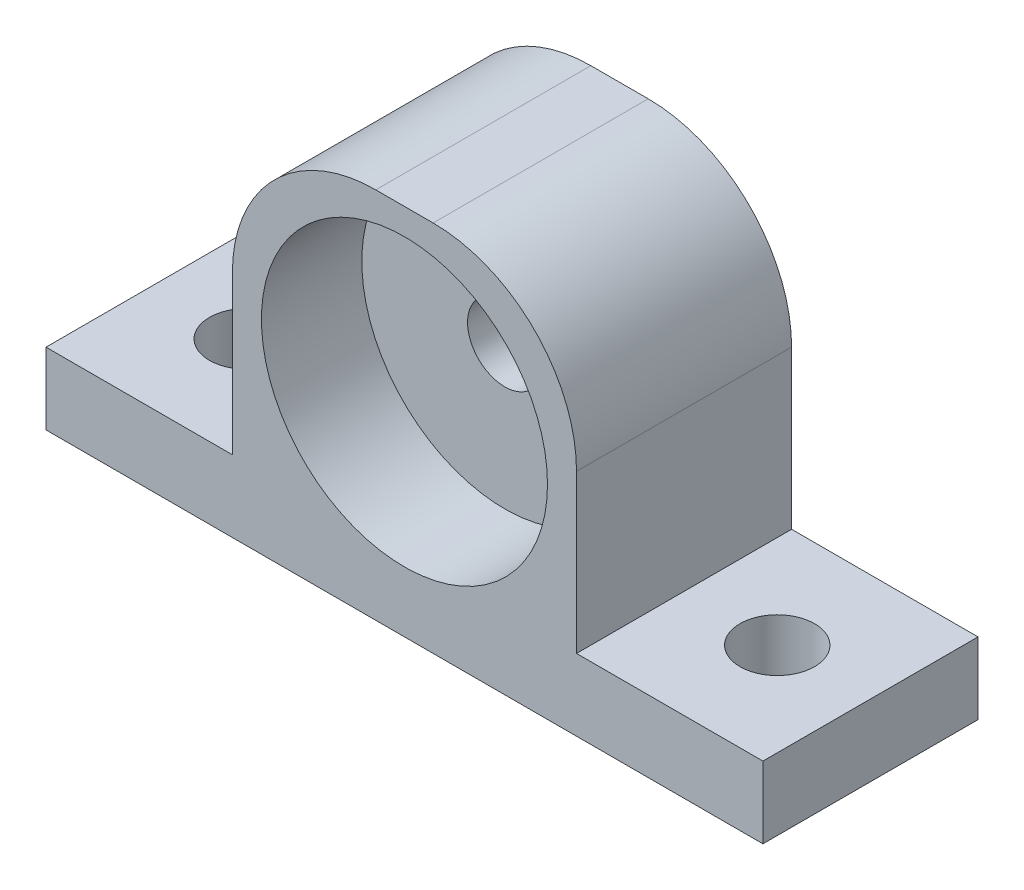
from build123d import *

# Parameters (mm, degrees)
SKETCH1_W           = 63.5
SKETCH1_H           = 19.05
BOSS_EXTRUDE1_DEPTH = 6.35
SKETCH2_W           = 30.48
SKETCH2_H           = 19.05
BOSS_EXTRUDE2_DEPTH = 26.67
CUT_EXTRUDE1_REACH  = 8.35
SKETCH3_R           = 3.302
SKETCH4_R           = 12.669104941
CUT_EXTRUDE2_DEPTH  = 8.89
SKETCH5_R           = 3.302
CUT_EXTRUDE3_DEPTH  = 20.05
FILLET1_R           = 12.7


with BuildPart() as part:
    # Sketch1 → Boss-Extrude1 (new body)
    with BuildSketch(Plane(origin=(0, 0, 0), x_dir=(1, 0, 0), z_dir=(0, 1, 0))):
        with Locations((-30.537406907, 4.286893637)):
            Rectangle(SKETCH1_W, SKETCH1_H)
    extrude(amount=BOSS_EXTRUDE1_DEPTH)

    # Sketch2 → Boss-Extrude2 (add)
    with BuildSketch(Plane(origin=(0, 6.35, 0), x_dir=(1, 0, 0), z_dir=(0, 1, 0))):
        with Locations((-30.537406907, 4.286893637)):
            Rectangle(SKETCH2_W, SKETCH2_H)
    extrude(amount=BOSS_EXTRUDE2_DEPTH)

    # Sketch3 → Cut-Extrude1 (cut, up to next)
    with BuildSketch(Plane(origin=(0, 6.35, 0), x_dir=(1, 0, 0), z_dir=(0, 1, 0)), mode=Mode.PRIVATE) as cut_extrude1_sk1:
        with Locations((-54.032406907, 4.286893637)):
            Circle(SKETCH3_R)
    cut_extrude1_tool1 = extrude(cut_extrude1_sk1.sketch, amount=-CUT_EXTRUDE1_REACH, mode=Mode.PRIVATE) & part.part
    add(cut_extrude1_tool1.solids().sort_by_distance((-54.032407, 6.35, -4.286894))[0], mode=Mode.SUBTRACT)
    # Sketch3 → Cut-Extrude1 (cut, up to next)
    with BuildSketch(Plane(origin=(0, 6.35, 0), x_dir=(1, 0, 0), z_dir=(0, 1, 0)), mode=Mode.PRIVATE) as cut_extrude1_sk2:
        with Locations((-7.042406907, 4.286893637)):
            Circle(SKETCH3_R)
    cut_extrude1_tool2 = extrude(cut_extrude1_sk2.sketch, amount=-CUT_EXTRUDE1_REACH, mode=Mode.PRIVATE) & part.part
    add(cut_extrude1_tool2.solids().sort_by_distance((-7.042407, 6.35, -4.286894))[0], mode=Mode.SUBTRACT)

    # Sketch4 → Cut-Extrude2 (cut)
    with BuildSketch(Plane.XY.offset(5.238106363)):
        with Locations((-30.537406907, 18.034)):
            Circle(SKETCH4_R)
    extrude(amount=-CUT_EXTRUDE2_DEPTH, mode=Mode.SUBTRACT)

    # Sketch5 → Cut-Extrude3 (cut, through all)
    with BuildSketch(Plane.XY.offset(5.238106363)):
        with Locations((-30.537406907, 18.034)):
            Circle(SKETCH5_R)
    extrude(amount=-CUT_EXTRUDE3_DEPTH, mode=Mode.SUBTRACT)

    # Fillet1
    fillet1_edges = [part.edges().sort_by_distance(p)[0] for p in [
        (-45.777406907, 33.02, -4.286893637),
        (-15.297406907, 33.02, -4.286893637),
    ]]
    fillet(fillet1_edges, radius=FILLET1_R)


solid = part.part
